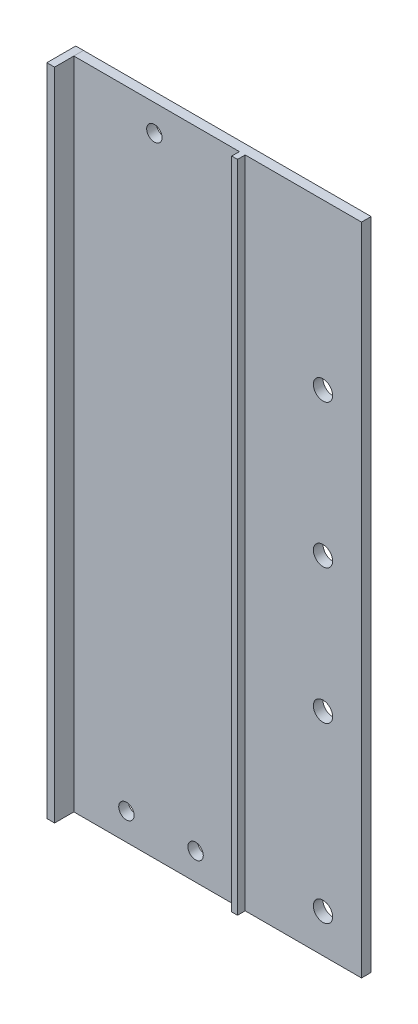
from build123d import *

# Parameters (mm, degrees)
SKETCH1_W           = 74.7
SKETCH1_H           = 170
SKETCH1_R           = 2
BOSS_EXTRUDE1_DEPTH = 2.5
BOSS_EXTRUDE2_START = -2.5
SKETCH2_W           = 2
SKETCH2_H           = 170
BOSS_EXTRUDE2_DEPTH = 7.5
SKETCH3_R           = 2.5
CUT_EXTRUDE1_DEPTH  = 5
SKETCH4_W           = 1.5
SKETCH4_H           = 170
BOSS_EXTRUDE3_DEPTH = 2
SKETCH5_R           = 2.5
CUT_EXTRUDE2_DEPTH  = 12


with BuildPart() as part:
    # Sketch1 → Boss-Extrude1 (new body)
    with BuildSketch(Plane.XY):
        with Locations((37.35, 85)):
            Rectangle(SKETCH1_W, SKETCH1_H)
        with Locations((20.913881882, 163.093745052)):
            Circle(SKETCH1_R, mode=Mode.SUBTRACT)
        with Locations((31.61325859, 7.021261507)):
            Circle(SKETCH1_R, mode=Mode.SUBTRACT)
        with Locations((13.651594244, 7.021261507)):
            Circle(SKETCH1_R, mode=Mode.SUBTRACT)
    extrude(amount=BOSS_EXTRUDE1_DEPTH)

    # Sketch3 → Cut-Extrude1 (cut)
    with BuildSketch(Plane(origin=(0, 0, 0), x_dir=(-1, 0, 0), z_dir=(0, 0, -1))):
        with Locations((-64.7, 10)):
            Circle(SKETCH3_R)
        with Locations((-64.7, 55)):
            Circle(SKETCH3_R)
        with Locations((-64.7, 90)):
            Circle(SKETCH3_R)
    extrude(amount=-CUT_EXTRUDE1_DEPTH, mode=Mode.SUBTRACT)

    # Sketch4 → Boss-Extrude3 (add)
    with BuildSketch(Plane.XY.offset(2.5)):
        with Locations((43.75, 85)):
            Rectangle(SKETCH4_W, SKETCH4_H)
    extrude(amount=BOSS_EXTRUDE3_DEPTH)

    # Sketch5 → Cut-Extrude2 (cut)
    with BuildSketch(Plane.XY.offset(2.5)):
        with Locations((64.7, 127.25)):
            Circle(SKETCH5_R)
    extrude(amount=-CUT_EXTRUDE2_DEPTH, mode=Mode.SUBTRACT)


with BuildPart() as body_2:
    # Sketch2 → Boss-Extrude2 (new body)
    with BuildSketch(Plane.XY.offset(2.5).offset(BOSS_EXTRUDE2_START)):
        with Locations((-1, 85)):
            Rectangle(SKETCH2_W, SKETCH2_H)
    extrude(amount=BOSS_EXTRUDE2_DEPTH)


solid = Compound([part.part, body_2.part])
